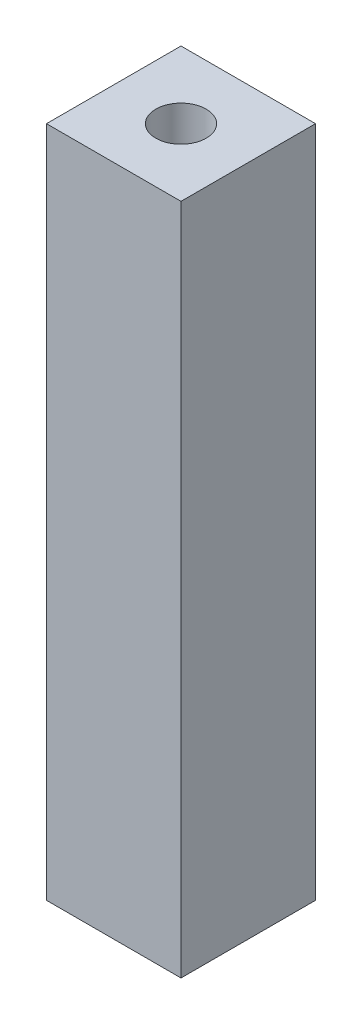
from build123d import *

# Parameters (mm, degrees)
SKETCH1_W           = 8
SKETCH1_H           = 8
BOSS_EXTRUDE1_DEPTH = 40
SKETCH2_R           = 1.5
CUT_EXTRUDE1_DEPTH  = 41


with BuildPart() as part:
    # Sketch1 → Boss-Extrude1 (new body)
    with BuildSketch(Plane(origin=(0, 0, 0), x_dir=(1, 0, 0), z_dir=(0, 1, 0))):
        Rectangle(SKETCH1_W, SKETCH1_H)
    extrude(amount=BOSS_EXTRUDE1_DEPTH)

    # Sketch2 → Cut-Extrude1 (cut, through all)
    with BuildSketch(Plane(origin=(0, 40, 0), x_dir=(1, 0, 0), z_dir=(0, 1, 0))):
        Circle(SKETCH2_R)
    extrude(amount=-CUT_EXTRUDE1_DEPTH, mode=Mode.SUBTRACT)


solid = part.part
